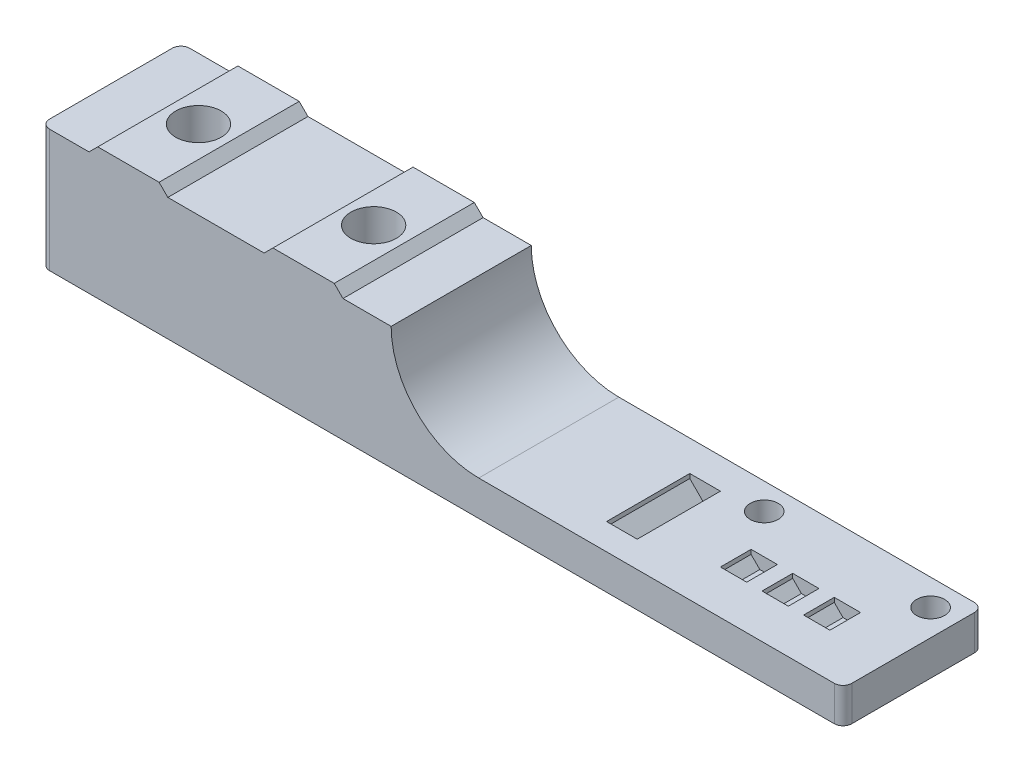
from build123d import *

# Parameters (mm, degrees)
BOSS_EXTRUDE1_DEPTH = 16
SKETCH2_R           = 2.6
CUT_EXTRUDE1_DEPTH  = 4.8
SKETCH3_R           = 4.5
CUT_EXTRUDE2_DEPTH  = 10
CUT_EXTRUDE3_REACH  = 17
SKETCH4_R           = 1.6
SKETCH5_W           = 3
SKETCH5_H           = 3.5
CUT_EXTRUDE4_DEPTH  = 1.5
CHAMFER1_SIZE       = 1
SKETCH6_W           = 3.5
SKETCH6_H           = 9.5
CUT_EXTRUDE5_DEPTH  = 2
CHAMFER2_SIZE       = 1.5
FILLET1_R           = 1


with BuildPart() as part:
    # Sketch1 → Boss-Extrude1 (new body)
    with BuildSketch(Plane.XY):
        with BuildLine():
            Line((0, 0), (91.6, 0))
            Line((91.6, 0), (91.6, 4))
            Line((91.6, 4), (50, 4))
            ThreePointArc((50, 4), (42.928932188, 6.928932188), (40, 14))
            Line((40, 14), (34.5, 14))
            Line((34.5, 14), (33.5, 15))
            Line((33.5, 15), (26.5, 15))
            Line((26.5, 15), (25.5, 14))
            Line((25.5, 14), (14.5, 14))
            Line((14.5, 14), (13.5, 15))
            Line((13.5, 15), (6.5, 15))
            Line((6.5, 15), (5.5, 14))
            Line((5.5, 14), (0, 14))
            Line((0, 14), (0, 0))
        make_face()
    extrude(amount=-BOSS_EXTRUDE1_DEPTH)

    # Sketch2 → Cut-Extrude1 (cut)
    with BuildSketch(Plane(origin=(0, 15, 0), x_dir=(1, 0, 0), z_dir=(0, 1, 0))):
        with Locations((10, 8)):
            Circle(SKETCH2_R)
        with Locations((30, 8)):
            Circle(SKETCH2_R)
    extrude(amount=-CUT_EXTRUDE1_DEPTH, mode=Mode.SUBTRACT)

    # Sketch3 → Cut-Extrude2 (cut)
    with BuildSketch(Plane.XZ):
        with Locations((10, -8)):
            Circle(SKETCH3_R)
        with Locations((30, -8)):
            Circle(SKETCH3_R)
    extrude(amount=-CUT_EXTRUDE2_DEPTH, mode=Mode.SUBTRACT)

    # Sketch4 → Cut-Extrude3 (cut, up to next)
    with BuildSketch(Plane.XZ, mode=Mode.PRIVATE) as cut_extrude3_sk1:
        with Locations((88.6, -13)):
            Circle(SKETCH4_R)
    cut_extrude3_tool1 = extrude(cut_extrude3_sk1.sketch, amount=-CUT_EXTRUDE3_REACH, mode=Mode.PRIVATE) & part.part
    add(cut_extrude3_tool1.solids().sort_by_distance((88.6, 0, -13))[0], mode=Mode.SUBTRACT)
    # Sketch4 → Cut-Extrude3 (cut, up to next)
    with BuildSketch(Plane.XZ, mode=Mode.PRIVATE) as cut_extrude3_sk2:
        with Locations((69.6, -13)):
            Circle(SKETCH4_R)
    cut_extrude3_tool2 = extrude(cut_extrude3_sk2.sketch, amount=-CUT_EXTRUDE3_REACH, mode=Mode.PRIVATE) & part.part
    add(cut_extrude3_tool2.solids().sort_by_distance((69.6, 0, -13))[0], mode=Mode.SUBTRACT)

    # Sketch5 → Cut-Extrude4 (cut)
    with BuildSketch(Plane(origin=(0, 4, 0), x_dir=(1, 0, 0), z_dir=(0, 1, 0))):
        with Locations((74.1, 6.75)):
            Rectangle(SKETCH5_W, SKETCH5_H)
        with Locations((78.85, 6.75)):
            Rectangle(SKETCH5_W, SKETCH5_H)
        with Locations((83.6, 6.75)):
            Rectangle(SKETCH5_W, SKETCH5_H)
    extrude(amount=-CUT_EXTRUDE4_DEPTH, mode=Mode.SUBTRACT)

    # Chamfer1
    chamfer1_edges = [part.edges().sort_by_distance(p)[0] for p in [
        (72.6, 2.5, -6.75),
        (75.6, 2.5, -6.75),
        (77.35, 2.5, -6.75),
        (80.35, 2.5, -6.75),
        (82.1, 2.5, -6.75),
        (85.1, 2.5, -6.75),
    ]]
    chamfer(chamfer1_edges, length=CHAMFER1_SIZE)

    # Sketch6 → Cut-Extrude5 (cut)
    with BuildSketch(Plane(origin=(0, 4, 0), x_dir=(1, 0, 0), z_dir=(0, 1, 0))):
        with Locations((63.35, 7.75)):
            Rectangle(SKETCH6_W, SKETCH6_H)
    extrude(amount=-CUT_EXTRUDE5_DEPTH, mode=Mode.SUBTRACT)

    # Chamfer2
    chamfer2_edges = [part.edges().sort_by_distance(p)[0] for p in [
        (65.1, 2, -7.75),
        (61.6, 2, -7.75),
    ]]
    chamfer(chamfer2_edges, length=CHAMFER2_SIZE)

    # Fillet1
    fillet1_edges = [part.edges().sort_by_distance(p)[0] for p in [
        (91.6, 2, -16),
        (91.6, 2, 0),
        (0, 7, 0),
        (0, 7, -16),
    ]]
    fillet(fillet1_edges, radius=FILLET1_R)


solid = part.part
